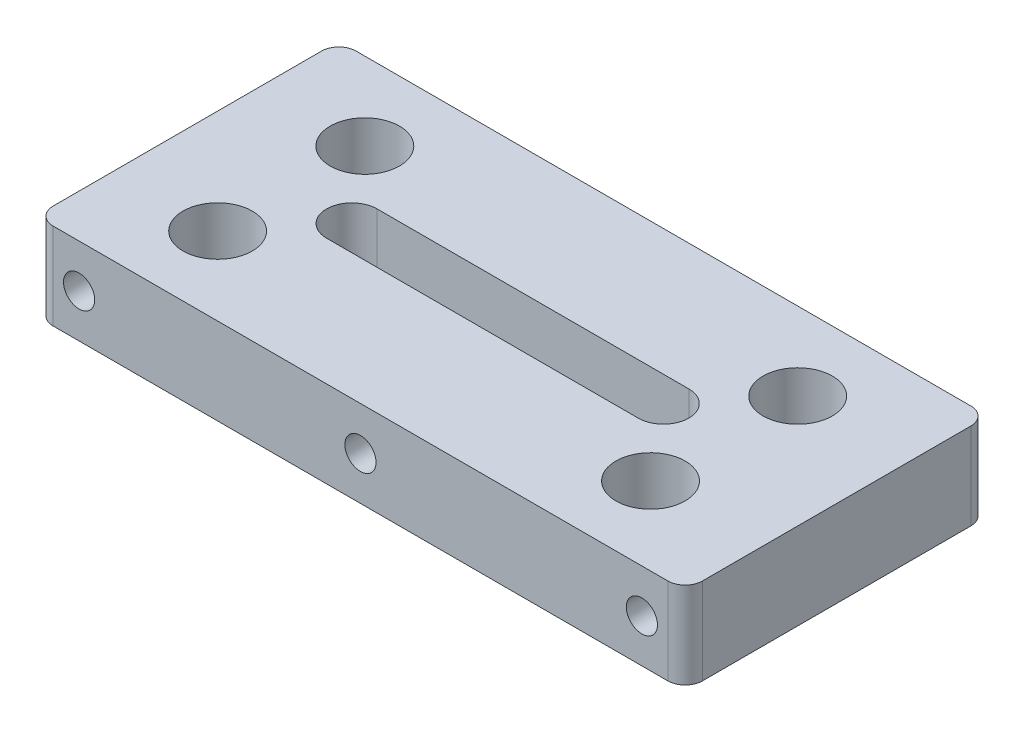
from build123d import *

# Parameters (mm, degrees)
SKETCH1_W           = 75
SKETCH1_H           = 35
BOSS_EXTRUDE1_DEPTH = 10
SKETCH2_R           = 1.8
CUT_EXTRUDE1_DEPTH  = 10
SKETCH3_R           = 1.8
CUT_EXTRUDE2_DEPTH  = 10
SKETCH4_R           = 4
CUT_EXTRUDE4_DEPTH  = 11
FILLET1_R           = 2


with BuildPart() as part:
    # Sketch1 → Boss-Extrude1 (new body)
    with BuildSketch(Plane(origin=(0, 0, 0), x_dir=(1, 0, 0), z_dir=(0, 1, 0))):
        with Locations((37.5, 17.5)):
            Rectangle(SKETCH1_W, SKETCH1_H)
    extrude(amount=BOSS_EXTRUDE1_DEPTH)

    # Sketch2 → Cut-Extrude1 (cut)
    with BuildSketch(Plane.XY):
        with Locations((5, 5)):
            Circle(SKETCH2_R)
        with Locations((37.5, 5)):
            Circle(SKETCH2_R)
        with Locations((70, 5)):
            Circle(SKETCH2_R)
    extrude(amount=-CUT_EXTRUDE1_DEPTH, mode=Mode.SUBTRACT)

    # Sketch3 → Cut-Extrude2 (cut)
    with BuildSketch(Plane(origin=(0, 0, -35), x_dir=(-1, 0, 0), z_dir=(0, 0, -1))):
        with Locations((-5, 5)):
            Circle(SKETCH3_R)
        with Locations((-37.5, 5)):
            Circle(SKETCH3_R)
        with Locations((-70, 5)):
            Circle(SKETCH3_R)
    extrude(amount=-CUT_EXTRUDE2_DEPTH, mode=Mode.SUBTRACT)

    # Sketch4 → Cut-Extrude4 (cut, through all)
    with BuildSketch(Plane.XZ):
        with Locations((12, -9)):
            Circle(SKETCH4_R)
        with Locations((62, -9)):
            Circle(SKETCH4_R)
        with Locations((62, -26)):
            Circle(SKETCH4_R)
        with Locations((12, -26)):
            Circle(SKETCH4_R)
        with BuildLine():
            Line((19, -14.576707994), (55, -14.576707994))
            ThreePointArc((55, -14.576707994), (57.923292006, -17.5), (55, -20.423292006))
            Line((55, -20.423292006), (19, -20.423292006))
            ThreePointArc((19, -20.423292006), (16.076707994, -17.5), (19, -14.576707994))
        make_face()
    extrude(amount=-CUT_EXTRUDE4_DEPTH, mode=Mode.SUBTRACT)

    # Fillet1
    fillet1_edges = [part.edges().sort_by_distance(p)[0] for p in [
        (0, 5, -35),
        (75, 5, -35),
        (75, 5, 0),
        (0, 5, 0),
    ]]
    fillet(fillet1_edges, radius=FILLET1_R)


solid = part.part
